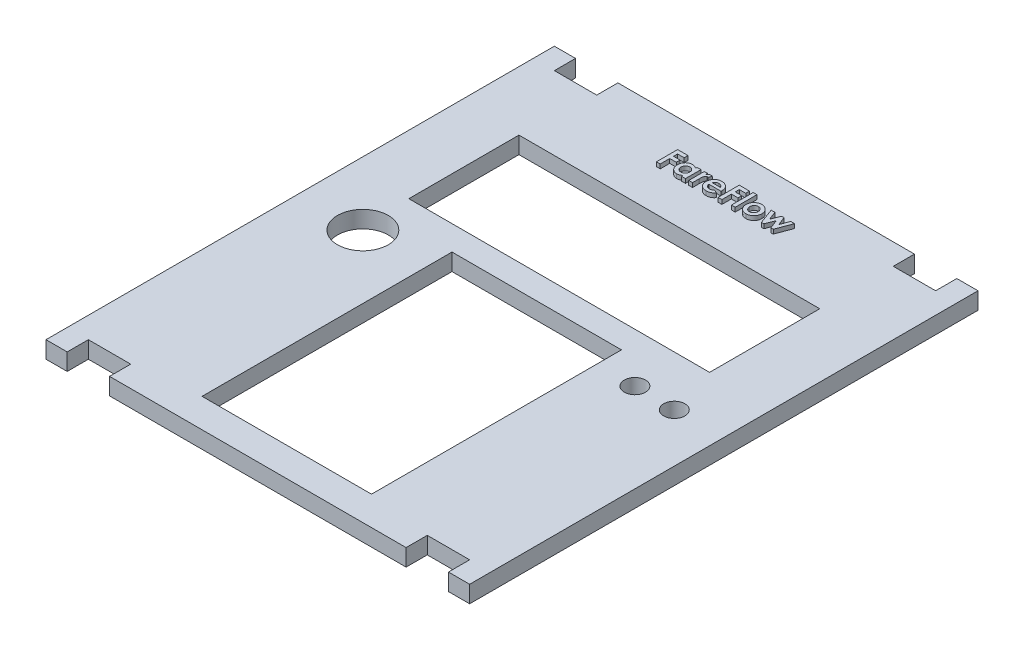
from build123d import *

# Parameters (mm, degrees)
SKETCH1_W           = 100
SKETCH1_H           = 120
BOSS_EXTRUDE1_DEPTH = 4
SKETCH3_R           = 6
SKETCH3_R_2         = 2.5
SKETCH3_W           = 71
SKETCH3_H           = 26
SKETCH3_W_2         = 40
SKETCH3_H_2         = 59
SKETCH3_W_3         = 10
SKETCH3_H_3         = 5
CUT_EXTRUDE1_DEPTH  = 5
SKETCH4_W           = 0.897435897
SKETCH4_H           = 5.128205128
BOSS_EXTRUDE2_DEPTH = 1


with BuildPart() as part:
    # Sketch1 → Boss-Extrude1 (new body)
    with BuildSketch(Plane(origin=(0, 0, 0), x_dir=(1, 0, 0), z_dir=(0, 1, 0))):
        Rectangle(SKETCH1_W, SKETCH1_H)
    extrude(amount=BOSS_EXTRUDE1_DEPTH)

    # Sketch3 → Cut-Extrude1 (cut, through all)
    with BuildSketch(Plane(origin=(0, 4, 0), x_dir=(1, 0, 0), z_dir=(0, 1, 0))):
        with Locations((-35, -0.197559239)):
            Circle(SKETCH3_R)
        with Locations((29, 0.011306219)):
            Circle(SKETCH3_R_2)
        with Locations((38.5, -0.189780712)):
            Circle(SKETCH3_R_2)
        with Locations((-0.5, 24.64453173)):
            Rectangle(SKETCH3_W, SKETCH3_H)
        with Locations((0, -23.662387578)):
            Rectangle(SKETCH3_W_2, SKETCH3_H_2)
        with Locations((-40, 57.5)):
            Rectangle(SKETCH3_W_3, SKETCH3_H_3)
        with Locations((40, 57.5)):
            Rectangle(SKETCH3_W_3, SKETCH3_H_3)
        with Locations((-40, -57.5)):
            Rectangle(SKETCH3_W_3, SKETCH3_H_3)
        with Locations((40, -57.5)):
            Rectangle(SKETCH3_W_3, SKETCH3_H_3)
    extrude(amount=-CUT_EXTRUDE1_DEPTH, mode=Mode.SUBTRACT)

    # Sketch4 → Boss-Extrude2 (add)
    with BuildSketch(Plane(origin=(0, 4, 0), x_dir=(1, 0, 0), z_dir=(0, 1, 0))):
        Polygon((-13.320028726, 52.413129682), (-10.88413129, 52.413129682), (-10.88413129, 51.515693784), (-12.422592829, 51.515693784), (-12.422592829, 50.554155323), (-10.88413129, 50.554155323), (-10.88413129, 49.656719425), (-12.422592829, 49.656719425), (-12.422592829, 47.413129682), (-13.320028726, 47.413129682), align=None)
        with BuildLine():
            Line((-7.358490265, 51.066975836), (-6.461054367, 51.066975836))
            Line((-6.461054367, 51.066975836), (-6.461054367, 47.413129682))
            Line((-6.461054367, 47.413129682), (-7.358490265, 47.413129682))
            Line((-7.358490265, 47.413129682), (-7.358490265, 47.811767502))
            add(Edge.make_bspline(
                [(-7.358490265, 47.811767502), (-7.402957883, 47.772964522), (-7.489260748, 47.697655601), (-7.625246138, 47.599940362), (-7.761628892, 47.519337917), (-7.899064335, 47.455142467), (-8.03966479, 47.407740733), (-8.184442526, 47.373420771), (-8.335482494, 47.35318145), (-8.438157384, 47.35042632), (-8.490301162, 47.349027118)],
                knots=[0, 0, 0, 0, 0.000176978, 0.000343479, 0.000501517, 0.00065164, 0.000797658, 0.000945854, 0.001097424, 0.001253831, 0.001253831, 0.001253831, 0.001253831], degree=3))
            add(Edge.make_bspline(
                [(-8.490301162, 47.349027118), (-8.548834871, 47.350343943), (-8.664500797, 47.352946064), (-8.834227702, 47.380337592), (-8.998115903, 47.422266431), (-9.156032367, 47.481600978), (-9.307689781, 47.558486919), (-9.454248783, 47.650918193), (-9.593196906, 47.762139689), (-9.725690844, 47.887339137), (-9.8470015, 48.02505942), (-9.95305242, 48.173389001), (-10.042445464, 48.330224151), (-10.115680401, 48.495044889), (-10.173289137, 48.667730247), (-10.214355922, 48.84882793), (-10.238585373, 49.038402617), (-10.241584296, 49.167533469), (-10.243105649, 49.233041541)],
                knots=[0, 0, 0, 0, 0.000175464, 0.000346726, 0.00051435, 0.000682339, 0.000851657, 0.001023656, 0.0012012, 0.001384701, 0.001569943, 0.001750881, 0.001930771, 0.002110572, 0.002291111, 0.002476017, 0.00266684, 0.002863318, 0.002863318, 0.002863318, 0.002863318], degree=3))
            add(Edge.make_bspline(
                [(-10.243105649, 49.233041541), (-10.241508983, 49.300875235), (-10.238376944, 49.433938584), (-10.215466269, 49.629202722), (-10.17515732, 49.814790707), (-10.120193171, 49.990959605), (-10.049491338, 50.157739851), (-9.963381229, 50.315404685), (-9.860691398, 50.463541995), (-9.742359571, 50.599630381), (-9.614590262, 50.724361961), (-9.477899689, 50.832950692), (-9.334425393, 50.925201872), (-9.184014908, 51.000514635), (-9.026689714, 51.058712526), (-8.863070928, 51.101259937), (-8.692432197, 51.126789878), (-8.576191711, 51.129637021), (-8.517344431, 51.1310784)],
                knots=[0, 0, 0, 0, 0.000203483, 0.000399155, 0.000588733, 0.000772466, 0.000951988, 0.001131286, 0.001310495, 0.001491597, 0.001671512, 0.001845456, 0.002014383, 0.002182357, 0.002349057, 0.002516681, 0.002688785, 0.002865249, 0.002865249, 0.002865249, 0.002865249], degree=3))
            add(Edge.make_bspline(
                [(-8.517344431, 51.1310784), (-8.462832783, 51.129945909), (-8.354973879, 51.127705117), (-8.19643683, 51.103374412), (-8.042678759, 51.066575948), (-7.894538423, 51.014144761), (-7.750800725, 50.94793972), (-7.613938046, 50.864979869), (-7.48095639, 50.768751974), (-7.399816672, 50.693595949), (-7.358490265, 50.655317182)],
                knots=[0, 0, 0, 0, 0.000163412, 0.000323333, 0.000480022, 0.000637143, 0.000793982, 0.000953904, 0.001116574, 0.001285426, 0.001285426, 0.001285426, 0.001285426], degree=3))
            Line((-7.358490265, 50.655317182), (-7.358490265, 51.066975836))
        make_face()
        with BuildLine():
            add(Edge.make_bspline(
                [(-8.329043149, 50.297745066), (-8.364803324, 50.296647821), (-8.434890933, 50.294497291), (-8.537964352, 50.281561704), (-8.63647162, 50.258768625), (-8.729710191, 50.225096744), (-8.819069662, 50.184079487), (-8.903193095, 50.132706048), (-8.982774787, 50.071983735), (-9.057346709, 50.003382634), (-9.125330004, 49.927977482), (-9.183935571, 49.845694123), (-9.233740836, 49.758749626), (-9.275863145, 49.66688258), (-9.306013162, 49.569005913), (-9.329891963, 49.466393805), (-9.342283514, 49.358207968), (-9.344529712, 49.284482668), (-9.345669752, 49.247063977)],
                knots=[0, 0, 0, 0, 0.000107288, 0.000210278, 0.000311102, 0.000409942, 0.00050718, 0.000605607, 0.000704968, 0.000807043, 0.000909187, 0.001008971, 0.001109476, 0.001209446, 0.001311442, 0.001416171, 0.001525125, 0.001637416, 0.001637416, 0.001637416, 0.001637416], degree=3))
            add(Edge.make_bspline(
                [(-9.345669752, 49.247063977), (-9.344547127, 49.209305875), (-9.342335006, 49.134903975), (-9.329691603, 49.025805552), (-9.30667206, 48.921694522), (-9.273087415, 48.823412553), (-9.232072773, 48.729633495), (-9.18214873, 48.640790148), (-9.120825787, 48.558453373), (-9.052782898, 48.480674806), (-8.976681145, 48.411221564), (-8.896649147, 48.349553462), (-8.811593732, 48.297955801), (-8.722437691, 48.256254244), (-8.629481126, 48.222270981), (-8.531558645, 48.199764364), (-8.429629521, 48.185376309), (-8.360141746, 48.183372679), (-8.325036739, 48.182360451)],
                knots=[0, 0, 0, 0, 0.000113292, 0.00022324, 0.000328946, 0.000432519, 0.000534318, 0.000635693, 0.000737463, 0.000841769, 0.00094526, 0.001046024, 0.001144451, 0.001243022, 0.001340918, 0.001440767, 0.001543888, 0.001649176, 0.001649176, 0.001649176, 0.001649176], degree=3))
            add(Edge.make_bspline(
                [(-8.325036739, 48.182360451), (-8.288610489, 48.183463848), (-8.217195237, 48.185627106), (-8.112440227, 48.198444641), (-8.012609653, 48.221321294), (-7.918118863, 48.255185954), (-7.827524602, 48.295908788), (-7.7416444, 48.34627835), (-7.661410187, 48.406861322), (-7.586415615, 48.476082579), (-7.517697545, 48.55210346), (-7.458281509, 48.635465835), (-7.406527968, 48.723503546), (-7.365826189, 48.818298125), (-7.333503268, 48.91819111), (-7.310312318, 49.023802458), (-7.297697786, 49.135246031), (-7.295505013, 49.211310612), (-7.294387701, 49.250068784)],
                knots=[0, 0, 0, 0, 0.000109289, 0.000214267, 0.000316066, 0.00041585, 0.000514908, 0.000613681, 0.000713841, 0.000815916, 0.000919475, 0.001020656, 0.00112253, 0.001225246, 0.001329456, 0.001437118, 0.001549056, 0.00166535, 0.00166535, 0.00166535, 0.00166535], degree=3))
            add(Edge.make_bspline(
                [(-7.294387701, 49.250068784), (-7.295491129, 49.288160334), (-7.297646446, 49.362564196), (-7.310366722, 49.471680879), (-7.333722314, 49.575218503), (-7.365379975, 49.673367382), (-7.406805852, 49.7659031), (-7.458598551, 49.851799657), (-7.517362828, 49.934033046), (-7.586841705, 50.008000182), (-7.661430015, 50.076720224), (-7.742844202, 50.135471123), (-7.828519277, 50.186104278), (-7.918981628, 50.227676051), (-8.015068897, 50.258149736), (-8.115070075, 50.281744396), (-8.220545387, 50.294489527), (-8.292287042, 50.296642178), (-8.329043149, 50.297745066)],
                knots=[0, 0, 0, 0, 0.000114292, 0.000223246, 0.000328952, 0.00043221, 0.000532179, 0.000632325, 0.000732695, 0.00083477, 0.00093617, 0.00103654, 0.001135313, 0.001234371, 0.001334461, 0.001437236, 0.001542214, 0.001652504, 0.001652504, 0.001652504, 0.001652504], degree=3))
        make_face(mode=Mode.SUBTRACT)
        with BuildLine():
            Line((-5.691823598, 51.066975836), (-4.922592829, 51.066975836))
            Line((-4.922592829, 51.066975836), (-4.922592829, 50.617256284))
            add(Edge.make_bspline(
                [(-4.922592829, 50.617256284), (-4.900832767, 50.657222984), (-4.858301824, 50.735339558), (-4.780168914, 50.840195589), (-4.690406662, 50.928502412), (-4.592240504, 51.002107046), (-4.485372917, 51.059474631), (-4.372665625, 51.100356267), (-4.255082837, 51.126923666), (-4.174871845, 51.129683516), (-4.134331611, 51.1310784)],
                knots=[0, 0, 0, 0, 0.000136409, 0.000266618, 0.000390562, 0.000512958, 0.000633505, 0.000752964, 0.000871818, 0.000993276, 0.000993276, 0.000993276, 0.000993276], degree=3))
            add(Edge.make_bspline(
                [(-4.134331611, 51.1310784), (-4.104894342, 51.129699963), (-4.044949551, 51.126892975), (-3.953585255, 51.110575909), (-3.860902732, 51.081071552), (-3.799909645, 51.054506799), (-3.768746675, 51.040934169)],
                knots=[0, 0, 0, 0, 8.8346e-05, 0.000179903, 0.000277476, 0.000379408, 0.000379408, 0.000379408, 0.000379408], degree=3))
            Line((-3.768746675, 51.040934169), (-4.047192188, 50.280717823))
            add(Edge.make_bspline(
                [(-4.047192188, 50.280717823), (-4.072081241, 50.29274301), (-4.118863078, 50.315345732), (-4.186782184, 50.342019272), (-4.248421589, 50.358294163), (-4.28749984, 50.36072252), (-4.305605649, 50.36184763)],
                knots=[0, 0, 0, 0, 8.2897e-05, 0.000155815, 0.000218733, 0.000273051, 0.000273051, 0.000273051, 0.000273051], degree=3))
            add(Edge.make_bspline(
                [(-4.305605649, 50.36184763), (-4.322701055, 50.361102073), (-4.356330663, 50.359635432), (-4.405967024, 50.34706682), (-4.45271414, 50.325392638), (-4.498824751, 50.29762586), (-4.540661242, 50.259027961), (-4.582471892, 50.21434404), (-4.619317676, 50.159175797), (-4.658200663, 50.09777074), (-4.691308136, 50.022611006), (-4.719696775, 49.932885771), (-4.74499128, 49.827556855), (-4.762397353, 49.706065011), (-4.779221021, 49.569585882), (-4.789234882, 49.41711773), (-4.796698339, 49.249142672), (-4.797154679, 49.13189002), (-4.797392508, 49.070781925)],
                knots=[0, 0, 0, 0, 5.1239e-05, 0.000100795, 0.000152356, 0.000205441, 0.000261504, 0.000322478, 0.000388614, 0.000460073, 0.000540314, 0.000634069, 0.000742177, 0.000864856, 0.001002014, 0.001154655, 0.001323071, 0.001506375, 0.001506375, 0.001506375, 0.001506375], degree=3))
            Line((-4.797392508, 49.070781925), (-4.794387701, 48.892496669))
            Line((-4.794387701, 48.892496669), (-4.794387701, 47.413129682))
            Line((-4.794387701, 47.413129682), (-5.691823598, 47.413129682))
            Line((-5.691823598, 47.413129682), (-5.691823598, 51.066975836))
        make_face()
        with BuildLine():
            Line((0.33081262, 49.015693784), (-2.550797957, 49.015693784))
            add(Edge.make_bspline(
                [(-2.550797957, 49.015693784), (-2.544922586, 48.982211104), (-2.533377018, 48.916414996), (-2.508305406, 48.82084044), (-2.47631027, 48.730772591), (-2.437966113, 48.646091052), (-2.393919419, 48.566348143), (-2.3425426, 48.49191789), (-2.284487324, 48.422866036), (-2.22008925, 48.359492686), (-2.150421779, 48.302708792), (-2.075822771, 48.25296251), (-1.996215244, 48.212173603), (-1.91251187, 48.177792786), (-1.824087191, 48.150559696), (-1.730811069, 48.131777552), (-1.632930764, 48.120682871), (-1.56625171, 48.119078152), (-1.532168149, 48.118257887)],
                knots=[0, 0, 0, 0, 0.000101952, 0.000200344, 0.000296017, 0.00038836, 0.000478932, 0.000568948, 0.000659231, 0.00074918, 0.000839597, 0.000928491, 0.00101764, 0.001107477, 0.001199674, 0.001294747, 0.001392525, 0.001494767, 0.001494767, 0.001494767, 0.001494767], degree=3))
            add(Edge.make_bspline(
                [(-1.532168149, 48.118257887), (-1.491026978, 48.119344054), (-1.410007894, 48.121483036), (-1.291314334, 48.140452629), (-1.176520372, 48.169105367), (-1.066712363, 48.211714394), (-0.960618353, 48.264755141), (-0.859984976, 48.330837386), (-0.763070348, 48.40802999), (-0.703941003, 48.467530019), (-0.673794752, 48.497865259)],
                knots=[0, 0, 0, 0, 0.000123344, 0.0002429, 0.000359749, 0.000477683, 0.000595489, 0.000714949, 0.000838211, 0.00096642, 0.00096642, 0.00096642, 0.00096642], degree=3))
            Line((-0.673794752, 48.497865259), (0.077407171, 48.140293143))
            add(Edge.make_bspline(
                [(0.077407171, 48.140293143), (0.053756017, 48.107610878), (0.006892125, 48.042852172), (-0.069611606, 47.951719947), (-0.149448121, 47.866689883), (-0.232676962, 47.788321238), (-0.319403683, 47.71683733), (-0.409387033, 47.651367356), (-0.50394208, 47.593669159), (-0.601178213, 47.540951335), (-0.703105485, 47.495756589), (-0.809441816, 47.457216105), (-0.919736812, 47.422375835), (-1.035383262, 47.395829458), (-1.155418179, 47.374815562), (-1.280128708, 47.359892912), (-1.409498414, 47.350675907), (-1.49743025, 47.349583242), (-1.542184175, 47.349027118)],
                knots=[0, 0, 0, 0, 0.000120995, 0.000239747, 0.000356661, 0.000470742, 0.000582442, 0.000693638, 0.000804269, 0.000914504, 0.001025253, 0.001138381, 0.0012537, 0.001372016, 0.001494035, 0.001619139, 0.00174866, 0.001882908, 0.001882908, 0.001882908, 0.001882908], degree=3))
            add(Edge.make_bspline(
                [(-1.542184175, 47.349027118), (-1.611037354, 47.350430827), (-1.745882335, 47.35317991), (-1.943117497, 47.378695339), (-2.130436195, 47.421002671), (-2.308367354, 47.478512991), (-2.476141834, 47.55444463), (-2.633842669, 47.647315323), (-2.783045515, 47.755344554), (-2.919191392, 47.880799567), (-3.043224303, 48.017349891), (-3.1521671, 48.163995614), (-3.243328881, 48.319712179), (-3.318192769, 48.48346902), (-3.376379584, 48.65568529), (-3.418328902, 48.836436142), (-3.444044337, 49.025635245), (-3.446821732, 49.154500955), (-3.448233855, 49.220020707)],
                knots=[0, 0, 0, 0, 0.000206486, 0.00040439, 0.000595379, 0.000781938, 0.000964386, 0.001146648, 0.001330157, 0.00151591, 0.00170099, 0.001882885, 0.002062912, 0.002241299, 0.002422156, 0.002607288, 0.002797247, 0.002993724, 0.002993724, 0.002993724, 0.002993724], degree=3))
            add(Edge.make_bspline(
                [(-3.448233855, 49.220020707), (-3.446807833, 49.287205401), (-3.444002201, 49.419388269), (-3.418550312, 49.612956066), (-3.376263609, 49.797645925), (-3.317906585, 49.973712185), (-3.244178391, 50.141705504), (-3.151856732, 50.300156143), (-3.043278365, 50.44961574), (-2.91969228, 50.589385108), (-2.782969647, 50.715542234), (-2.637688932, 50.827973444), (-2.482217757, 50.92165859), (-2.318314636, 50.997356131), (-2.147027952, 51.058858472), (-1.966377869, 51.099783144), (-1.777738861, 51.127261611), (-1.648789389, 51.129792206), (-1.58324988, 51.1310784)],
                knots=[0, 0, 0, 0, 0.000201482, 0.000396406, 0.000584465, 0.000769121, 0.000952075, 0.001133832, 0.001318151, 0.00150547, 0.001692579, 0.00187548, 0.002055672, 0.002235807, 0.002416373, 0.002600529, 0.002790623, 0.0029871, 0.0029871, 0.0029871, 0.0029871], degree=3))
            add(Edge.make_bspline(
                [(-1.58324988, 51.1310784), (-1.514066848, 51.129652913), (-1.378233095, 51.126854117), (-1.179624251, 51.101545867), (-0.991061779, 51.05898055), (-0.811742297, 51.001967511), (-0.643955788, 50.924117759), (-0.484015475, 50.833532467), (-0.335757632, 50.723168103), (-0.19760199, 50.598327026), (-0.072888287, 50.459820177), (0.036125308, 50.309359318), (0.12888246, 50.148412858), (0.204063052, 49.976328124), (0.262190119, 49.793621733), (0.304178269, 49.600530964), (0.329697556, 49.396321392), (0.33242327, 49.256487395), (0.333817428, 49.184964618)],
                knots=[0, 0, 0, 0, 0.000207487, 0.000407378, 0.000599344, 0.000786855, 0.000970629, 0.001153254, 0.001337355, 0.00152385, 0.001711088, 0.001895407, 0.002080267, 0.002267291, 0.002457661, 0.002654516, 0.002859378, 0.003073871, 0.003073871, 0.003073871, 0.003073871], degree=3))
            Line((0.333817428, 49.184964618), (0.33081262, 49.015693784))
        make_face()
        with BuildLine():
            add(Edge.make_bspline(
                [(-0.56361847, 49.720821989), (-0.580553634, 49.766523138), (-0.614225152, 49.857388926), (-0.690287711, 49.982761541), (-0.791220292, 50.091339319), (-0.908612124, 50.187464086), (-1.042739644, 50.265484951), (-1.189376257, 50.321974591), (-1.346668506, 50.355846488), (-1.454877096, 50.359819067), (-1.510132893, 50.36184763)],
                knots=[0, 0, 0, 0, 0.000146007, 0.000290301, 0.00043637, 0.000588732, 0.000744029, 0.000899716, 0.001058444, 0.001224075, 0.001224075, 0.001224075, 0.001224075], degree=3))
            add(Edge.make_bspline(
                [(-1.510132893, 50.36184763), (-1.570481219, 50.359898948), (-1.688449631, 50.35608968), (-1.858611034, 50.315576719), (-2.019120027, 50.255112334), (-2.113747032, 50.192772269), (-2.16117456, 50.161527118)],
                knots=[0, 0, 0, 0, 0.000180689, 0.000353209, 0.000522278, 0.000692164, 0.000692164, 0.000692164, 0.000692164], degree=3))
            add(Edge.make_bspline(
                [(-2.16117456, 50.161527118), (-2.190765795, 50.137730126), (-2.253852795, 50.086996155), (-2.335784064, 49.985786701), (-2.416487046, 49.863244772), (-2.462371141, 49.770165519), (-2.486695393, 49.720821989)],
                knots=[0, 0, 0, 0, 0.000113637, 0.000242268, 0.000388392, 0.000553252, 0.000553252, 0.000553252, 0.000553252], degree=3))
            Line((-2.486695393, 49.720821989), (-0.56361847, 49.720821989))
        make_face(mode=Mode.SUBTRACT)
        Polygon((1.231253325, 52.413129682), (3.667150761, 52.413129682), (3.667150761, 51.515693784), (2.128689222, 51.515693784), (2.128689222, 50.554155323), (3.667150761, 50.554155323), (3.667150761, 49.656719425), (2.128689222, 49.656719425), (2.128689222, 47.413129682), (1.231253325, 47.413129682), align=None)
        with Locations((4.820996915, 49.977232246)):
            Rectangle(SKETCH4_W, SKETCH4_H)
        with BuildLine():
            add(Edge.make_bspline(
                [(7.843833453, 51.1310784), (7.88626249, 51.130323346), (7.970291208, 51.128827997), (8.095441487, 51.116380586), (8.21840385, 51.096072122), (8.339885069, 51.069776206), (8.458757077, 51.032931694), (8.575643344, 50.988742399), (8.69158898, 50.93800792), (8.80371624, 50.877616146), (8.912835158, 50.812115758), (9.016286386, 50.739863456), (9.113210833, 50.661426757), (9.205407747, 50.578624278), (9.288580604, 50.487851069), (9.368044593, 50.393480963), (9.439506471, 50.29213301), (9.505669876, 50.186276824), (9.564574679, 50.076524551), (9.615722667, 49.963639666), (9.660114312, 49.849182885), (9.694872081, 49.731760043), (9.72364831, 49.612919518), (9.741808155, 49.491205008), (9.754718546, 49.367866826), (9.75616621, 49.284825413), (9.756894351, 49.243057566)],
                knots=[0, 0, 0, 0, 0.000127267, 0.000252046, 0.000376861, 0.000501035, 0.000624602, 0.000749803, 0.000875806, 0.001003952, 0.001131581, 0.001257452, 0.001382123, 0.001505487, 0.001628794, 0.001751137, 0.001875372, 0.00200044, 0.002125464, 0.002248726, 0.002372053, 0.002493413, 0.002615858, 0.002738537, 0.002862319, 0.002987584, 0.002987584, 0.002987584, 0.002987584], degree=3))
            add(Edge.make_bspline(
                [(9.756894351, 49.243057566), (9.756125919, 49.200963408), (9.754598103, 49.11727068), (9.742275237, 48.99277235), (9.721889039, 48.870485474), (9.695492197, 48.749689637), (9.658785568, 48.631930538), (9.61589779, 48.515472362), (9.563251354, 48.401902478), (9.505046841, 48.289981944), (9.438458034, 48.18300424), (9.367058014, 48.080641025), (9.287926859, 47.985577765), (9.205419825, 47.894866286), (9.115623416, 47.811574044), (9.019970952, 47.734348593), (8.919290516, 47.662245819), (8.812858111, 47.596957389), (8.702036957, 47.539590774), (8.588696034, 47.487870089), (8.472172585, 47.444808926), (8.352707763, 47.409693733), (8.230229116, 47.382504918), (8.105007045, 47.364035232), (7.977311233, 47.351189779), (7.891274823, 47.349752646), (7.847839863, 47.349027118)],
                knots=[0, 0, 0, 0, 0.000126266, 0.000251044, 0.000374871, 0.000498068, 0.000621635, 0.000744608, 0.000870109, 0.000996901, 0.001122821, 0.001247873, 0.001370988, 0.001493614, 0.001615506, 0.001737988, 0.001862223, 0.001986765, 0.002112205, 0.00223638, 0.002360291, 0.00248453, 0.002609683, 0.002736321, 0.002864091, 0.002994361, 0.002994361, 0.002994361, 0.002994361], degree=3))
            add(Edge.make_bspline(
                [(7.847839863, 47.349027118), (7.784329096, 47.350891284), (7.659148407, 47.354565584), (7.474786847, 47.379733578), (7.297676248, 47.423054295), (7.127528008, 47.483442419), (6.964121101, 47.560827549), (6.808881613, 47.656603399), (6.660265333, 47.768884417), (6.520846407, 47.896721594), (6.393119784, 48.036970553), (6.281535211, 48.186685463), (6.186790879, 48.343622348), (6.108972029, 48.507960169), (6.048911745, 48.679924278), (6.005537973, 48.859000562), (5.980339208, 49.045692378), (5.976695984, 49.172536184), (5.974843069, 49.237047951)],
                knots=[0, 0, 0, 0, 0.000190518, 0.000375514, 0.000556981, 0.000736603, 0.000916259, 0.001098347, 0.001282843, 0.001474256, 0.001664995, 0.001851094, 0.002033518, 0.002214079, 0.00239559, 0.002579004, 0.002765984, 0.002959504, 0.002959504, 0.002959504, 0.002959504], degree=3))
            add(Edge.make_bspline(
                [(5.974843069, 49.237047951), (5.976760601, 49.305932376), (5.980529471, 49.441323335), (6.010455964, 49.639674175), (6.058245344, 49.829585703), (6.12684399, 50.010526679), (6.214472726, 50.182830821), (6.321447553, 50.346134723), (6.448297148, 50.500475374), (6.545438537, 50.593825891), (6.594835056, 50.641294746)],
                knots=[0, 0, 0, 0, 0.000206573, 0.000406015, 0.000600357, 0.000793082, 0.000985249, 0.001179156, 0.001377678, 0.001583068, 0.001583068, 0.001583068, 0.001583068], degree=3))
            add(Edge.make_bspline(
                [(6.594835056, 50.641294746), (6.640161299, 50.680641087), (6.729580594, 50.758263274), (6.874857518, 50.856714293), (7.023604696, 50.941745937), (7.177604925, 51.011657763), (7.337287519, 51.064370153), (7.501834195, 51.102740056), (7.671210738, 51.126307975), (7.786000132, 51.129480177), (7.843833453, 51.1310784)],
                knots=[0, 0, 0, 0, 0.000179924, 0.000354952, 0.000525401, 0.000693509, 0.000861379, 0.001029018, 0.001199849, 0.001373311, 0.001373311, 0.001373311, 0.001373311], degree=3))
        make_face()
        with BuildLine():
            add(Edge.make_bspline(
                [(7.863865504, 50.297745066), (7.829119249, 50.296590216), (7.760720872, 50.29431688), (7.660036663, 50.282116496), (7.564808479, 50.25711076), (7.473144908, 50.225310308), (7.38666749, 50.182781683), (7.303007916, 50.133013392), (7.226516299, 50.070734499), (7.153490966, 50.00241911), (7.087200241, 49.926556705), (7.030714248, 49.84390467), (6.980242762, 49.757625101), (6.941972794, 49.664559194), (6.910300736, 49.567250711), (6.888865468, 49.464127442), (6.873948018, 49.356341332), (6.872840608, 49.282507107), (6.872278966, 49.245060771)],
                knots=[0, 0, 0, 0, 0.000104287, 0.00020529, 0.000303432, 0.000399104, 0.000495867, 0.000592062, 0.000690454, 0.000791064, 0.000891883, 0.000991908, 0.001091047, 0.001191132, 0.001293128, 0.001397641, 0.001506719, 0.00161897, 0.00161897, 0.00161897, 0.00161897], degree=3))
            add(Edge.make_bspline(
                [(6.872278966, 49.245060771), (6.872936164, 49.206293889), (6.874220531, 49.130531462), (6.887520419, 49.019908131), (6.909452374, 48.914927323), (6.940610808, 48.815751211), (6.9797978, 48.721667921), (7.027875695, 48.633205323), (7.085351902, 48.55089531), (7.150515969, 48.474839239), (7.22186784, 48.405802302), (7.300049642, 48.346557386), (7.381787416, 48.295081417), (7.468964843, 48.253738269), (7.560343754, 48.221818005), (7.656195416, 48.198316187), (7.757023529, 48.185654548), (7.825772367, 48.183473582), (7.860860697, 48.182360451)],
                knots=[0, 0, 0, 0, 0.000116255, 0.000227198, 0.00033367, 0.000437576, 0.000538584, 0.000638984, 0.000739009, 0.000839175, 0.000939059, 0.00103622, 0.001132941, 0.001228367, 0.001324984, 0.001422885, 0.001523888, 0.001629175, 0.001629175, 0.001629175, 0.001629175], degree=3))
            add(Edge.make_bspline(
                [(7.860860697, 48.182360451), (7.895966576, 48.183347748), (7.964794478, 48.185283422), (8.065740994, 48.199778569), (8.162082145, 48.222591073), (8.254241504, 48.254786065), (8.341473953, 48.297014141), (8.424113428, 48.348736378), (8.502886916, 48.408805337), (8.575196336, 48.47914487), (8.642131783, 48.555438132), (8.700830167, 48.638182654), (8.74988075, 48.726645275), (8.790111011, 48.820269385), (8.821330527, 48.9189263), (8.842899394, 49.022982716), (8.857824819, 49.132116153), (8.858907183, 49.206947609), (8.859458453, 49.245060771)],
                knots=[0, 0, 0, 0, 0.000105287, 0.000206425, 0.000305299, 0.000401916, 0.000498679, 0.0005954, 0.000693965, 0.000795265, 0.000897497, 0.000998097, 0.001098981, 0.001200381, 0.001303332, 0.001408824, 0.001518895, 0.001633148, 0.001633148, 0.001633148, 0.001633148], degree=3))
            add(Edge.make_bspline(
                [(8.859458453, 49.245060771), (8.858792895, 49.283160613), (8.857486854, 49.357924862), (8.844186018, 49.467205901), (8.822469297, 49.570925976), (8.790908988, 49.668642214), (8.751954917, 49.7614694), (8.703843791, 49.848932388), (8.646084131, 49.930600399), (8.580603282, 50.006068479), (8.508181802, 50.074136671), (8.431357425, 50.134836974), (8.348373412, 50.185040788), (8.260786596, 50.226426652), (8.168363947, 50.258267167), (8.071209227, 50.281902175), (7.969024687, 50.294383645), (7.899284912, 50.296612882), (7.863865504, 50.297745066)],
                knots=[0, 0, 0, 0, 0.000114253, 0.000224201, 0.000329693, 0.00043169, 0.000531775, 0.000631297, 0.000730501, 0.00083132, 0.000930515, 0.001028288, 0.001124483, 0.001220814, 0.001318377, 0.001417252, 0.001520242, 0.001626529, 0.001626529, 0.001626529, 0.001626529], degree=3))
        make_face(mode=Mode.SUBTRACT)
        Polygon((10.109458453, 51.066975836), (11.004891145, 51.066975836), (11.77612512, 48.988650515), (12.59243121, 51.066975836), (13.142311017, 51.066975836), (13.955612299, 49.011687374), (14.723841466, 51.066975836), (15.622278966, 51.066975836), (14.256093069, 47.413129682), (13.69018762, 47.413129682), (12.86586871, 49.495461412), (12.047559415, 47.413129682), (11.464626722, 47.413129682), align=None)
    extrude(amount=BOSS_EXTRUDE2_DEPTH)


solid = part.part
